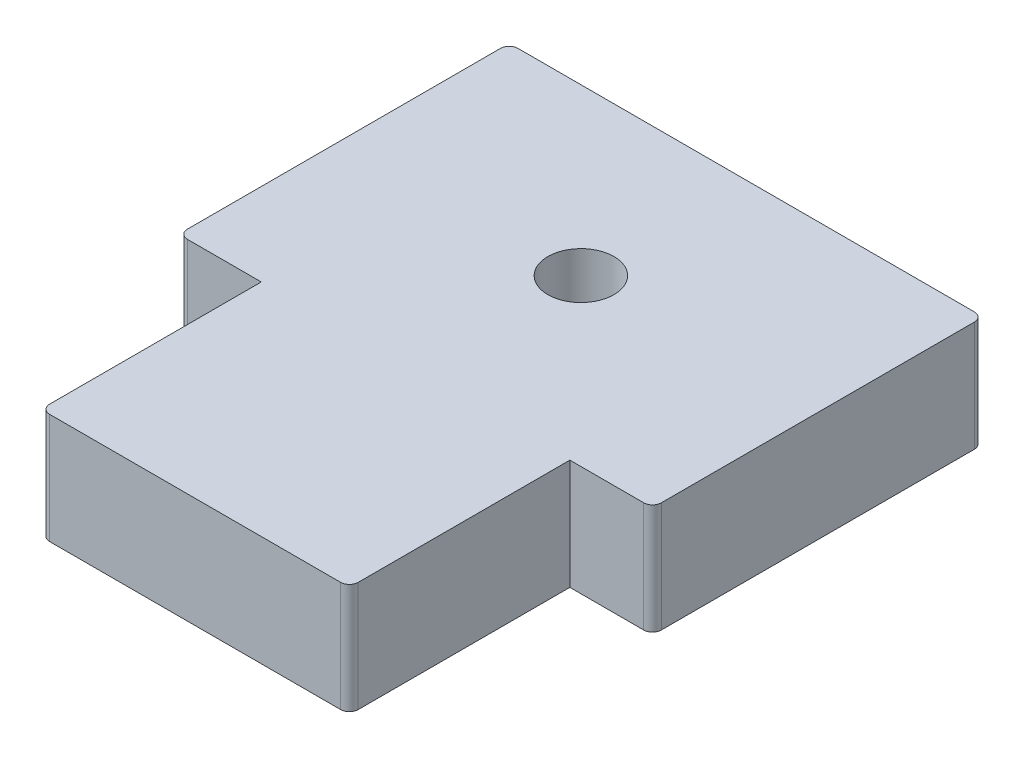
from build123d import *

# Parameters (mm, degrees)
BOSS_EXTRUDE1_DEPTH = 100
FILLET2_R           = 8
SKETCH2_R           = 30
CUT_EXTRUDE1_DEPTH  = 80


with BuildPart() as part:
    # Sketch1 → Boss-Extrude1 (new body)
    with BuildSketch(Plane(origin=(0, 0, 0), x_dir=(1, 0, 0), z_dir=(0, 1, 0))):
        Polygon((-140, -150), (-140, -350), (140, -350), (140, -150), (215, -150), (215, 150), (-215, 150), (-215, -150), align=None)
    extrude(amount=BOSS_EXTRUDE1_DEPTH)

    # Fillet2
    fillet2_edges = [part.edges().sort_by_distance(p)[0] for p in [
        (140, 50, 350),
        (-140, 50, 350),
        (-215, 50, 150),
        (-215, 50, -150),
        (215, 50, -150),
        (215, 50, 150),
    ]]
    fillet(fillet2_edges, radius=FILLET2_R)

    # Sketch2 → Cut-Extrude1 (cut)
    with BuildSketch(Plane(origin=(0, 100, 0), x_dir=(1, 0, 0), z_dir=(0, 1, 0))):
        Circle(SKETCH2_R)
    extrude(amount=-CUT_EXTRUDE1_DEPTH, mode=Mode.SUBTRACT)


solid = part.part
